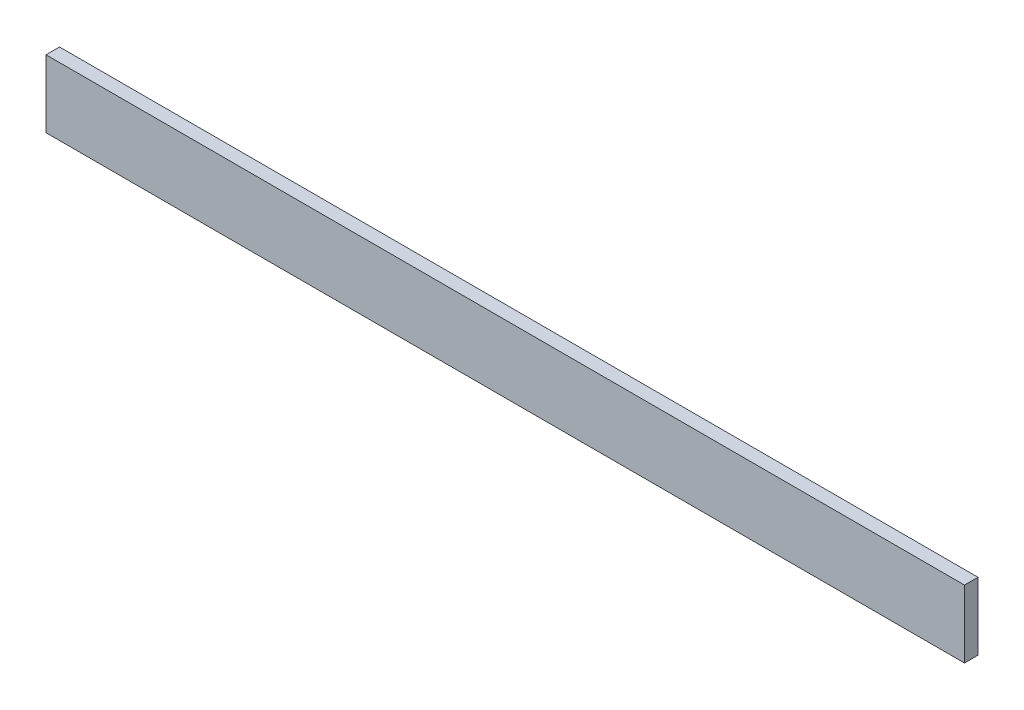
from build123d import *

# Parameters (mm, degrees)
SKETCH_1_W      = 10
SKETCH_1_H      = 50
EXTRUDE_1_DEPTH = 680


with BuildPart() as part:
    # Эскиз1 → Бобышка-Вытянуть1 (new body)
    with BuildSketch(Plane(origin=(0, 0, 0), x_dir=(0, 0, -1), z_dir=(1, 0, 0))):
        with Locations((5, 25)):
            Rectangle(SKETCH_1_W, SKETCH_1_H)
    extrude(amount=EXTRUDE_1_DEPTH)


solid = part.part
